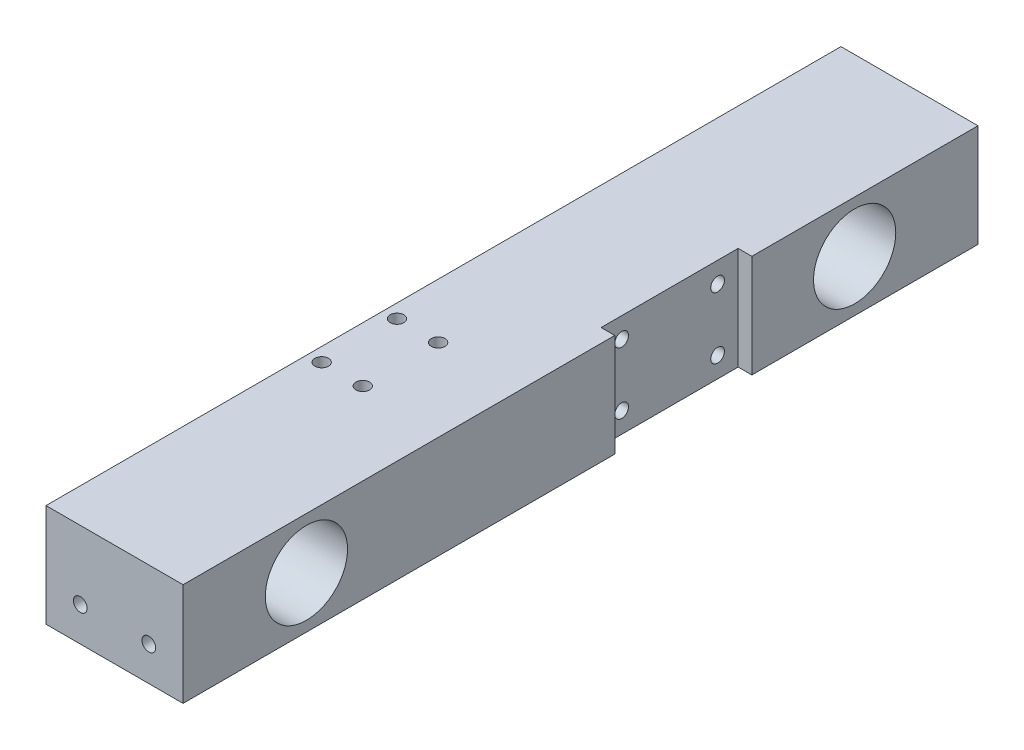
from build123d import *

# Parameters (mm, degrees)
SKETCH1_W           = 20
SKETCH1_H           = 15
BOSS_EXTRUDE1_DEPTH = 116
SKETCH1_5_R         = 1
CUT_EXTRUDE1_DEPTH  = 10
SKETCH4_R           = 1
CUT_EXTRUDE2_DEPTH  = 10
SKETCH5_R           = 2.5
CUT_EXTRUDE3_DEPTH  = 21
SKETCH6_R           = 6
CUT_EXTRUDE4_DEPTH  = 21
SKETCH8_R           = 1
CUT_EXTRUDE5_DEPTH  = 16
SKETCH9_R           = 1.5
CUT_EXTRUDE6_DEPTH  = 5
SKETCH10_R          = 1
CUT_EXTRUDE7_DEPTH  = 21
SKETCH11_R          = 2
CUT_EXTRUDE8_DEPTH  = 5
SKETCH10_3_W        = 10
SKETCH10_3_H        = 7.5
SKETCH10_3_R        = 1
CUT_EXTRUDE9_DEPTH  = 2


with BuildPart() as part:
    # Sketch1 → Boss-Extrude1 (new body)
    with BuildSketch(Plane.XY):
        with Locations((10, 7.5)):
            Rectangle(SKETCH1_W, SKETCH1_H)
    extrude(amount=BOSS_EXTRUDE1_DEPTH)

    # Sketch1_5 → Cut-Extrude1 (cut)
    with BuildSketch(Plane.XY):
        with Locations((15, 5)):
            Circle(SKETCH1_5_R)
        with Locations((5, 5)):
            Circle(SKETCH1_5_R)
    extrude(amount=CUT_EXTRUDE1_DEPTH, mode=Mode.SUBTRACT)

    # Sketch4 → Cut-Extrude2 (cut)
    with BuildSketch(Plane.XY.offset(116)):
        with Locations((5, 5)):
            Circle(SKETCH4_R)
        with Locations((15, 5)):
            Circle(SKETCH4_R)
    extrude(amount=-CUT_EXTRUDE2_DEPTH, mode=Mode.SUBTRACT)

    # Sketch5 → Cut-Extrude3 (cut, through all)
    with BuildSketch(Plane(origin=(20, 0, 0), x_dir=(0, 0, -1), z_dir=(1, 0, 0))):
        with Locations((-98, 7.5)):
            Circle(SKETCH5_R)
        with Locations((-18, 7.5)):
            Circle(SKETCH5_R)
    extrude(amount=-CUT_EXTRUDE3_DEPTH, mode=Mode.SUBTRACT)

    # Sketch6 → Cut-Extrude4 (cut, through all)
    with BuildSketch(Plane(origin=(20, 0, 0), x_dir=(0, 0, -1), z_dir=(1, 0, 0))):
        with Locations((-98, 7.5)):
            Circle(SKETCH6_R)
        with Locations((-18, 7.5)):
            Circle(SKETCH6_R)
    extrude(amount=-CUT_EXTRUDE4_DEPTH, mode=Mode.SUBTRACT)

    # Sketch8 → Cut-Extrude5 (cut, through all)
    with BuildSketch(Plane(origin=(0, 15, 0), x_dir=(1, 0, 0), z_dir=(0, 1, 0))):
        with Locations((8, -77.78)):
            Circle(SKETCH8_R)
        with Locations((2, -66.78)):
            Circle(SKETCH8_R)
        with Locations((8, -66.78)):
            Circle(SKETCH8_R)
        with Locations((2, -77.78)):
            Circle(SKETCH8_R)
    extrude(amount=-CUT_EXTRUDE5_DEPTH, mode=Mode.SUBTRACT)

    # Sketch9 → Cut-Extrude6 (cut)
    with BuildSketch(Plane(origin=(0, 0, 0), x_dir=(-1, 0, 0), z_dir=(0, -1, 0))):
        with Locations((-2, -77.78)):
            Circle(SKETCH9_R)
        with Locations((-8, -77.78)):
            Circle(SKETCH9_R)
        with Locations((-8, -66.78)):
            Circle(SKETCH9_R)
        with Locations((-2, -66.78)):
            Circle(SKETCH9_R)
    extrude(amount=-CUT_EXTRUDE6_DEPTH, mode=Mode.SUBTRACT)

    # Sketch10 → Cut-Extrude7 (cut, through all)
    with BuildSketch(Plane(origin=(20, 0, 0), x_dir=(0, 0, -1), z_dir=(1, 0, 0))):
        with Locations((-50, 12)):
            Circle(SKETCH10_R)
        with Locations((-36, 12)):
            Circle(SKETCH10_R)
        with Locations((-36, 3)):
            Circle(SKETCH10_R)
        with Locations((-50, 3)):
            Circle(SKETCH10_R)
    extrude(amount=-CUT_EXTRUDE7_DEPTH, mode=Mode.SUBTRACT)

    # Sketch11 → Cut-Extrude8 (cut)
    with BuildSketch(Plane.ZY):
        with Locations((36, 12)):
            Circle(SKETCH11_R)
        with Locations((36, 3)):
            Circle(SKETCH11_R)
        with Locations((50, 3)):
            Circle(SKETCH11_R)
        with Locations((50, 12)):
            Circle(SKETCH11_R)
    extrude(amount=-CUT_EXTRUDE8_DEPTH, mode=Mode.SUBTRACT)

    # Sketch10_3 → Cut-Extrude9 (cut)
    with BuildSketch(Plane(origin=(20, 0, 0), x_dir=(0, 0, -1), z_dir=(1, 0, 0))):
        with Locations((-48, 11.25)):
            Rectangle(SKETCH10_3_W, SKETCH10_3_H)
        with Locations((-50, 12)):
            Circle(SKETCH10_3_R, mode=Mode.SUBTRACT)
        with Locations((-38, 11.25)):
            Rectangle(SKETCH10_3_W, SKETCH10_3_H)
        with Locations((-36, 12)):
            Circle(SKETCH10_3_R, mode=Mode.SUBTRACT)
        with Locations((-38, 3.75)):
            Rectangle(SKETCH10_3_W, SKETCH10_3_H)
        with Locations((-36, 3)):
            Circle(SKETCH10_3_R, mode=Mode.SUBTRACT)
        with Locations((-48, 3.75)):
            Rectangle(SKETCH10_3_W, SKETCH10_3_H)
        with Locations((-50, 3)):
            Circle(SKETCH10_3_R, mode=Mode.SUBTRACT)
    extrude(amount=-CUT_EXTRUDE9_DEPTH, mode=Mode.SUBTRACT)


solid = part.part
